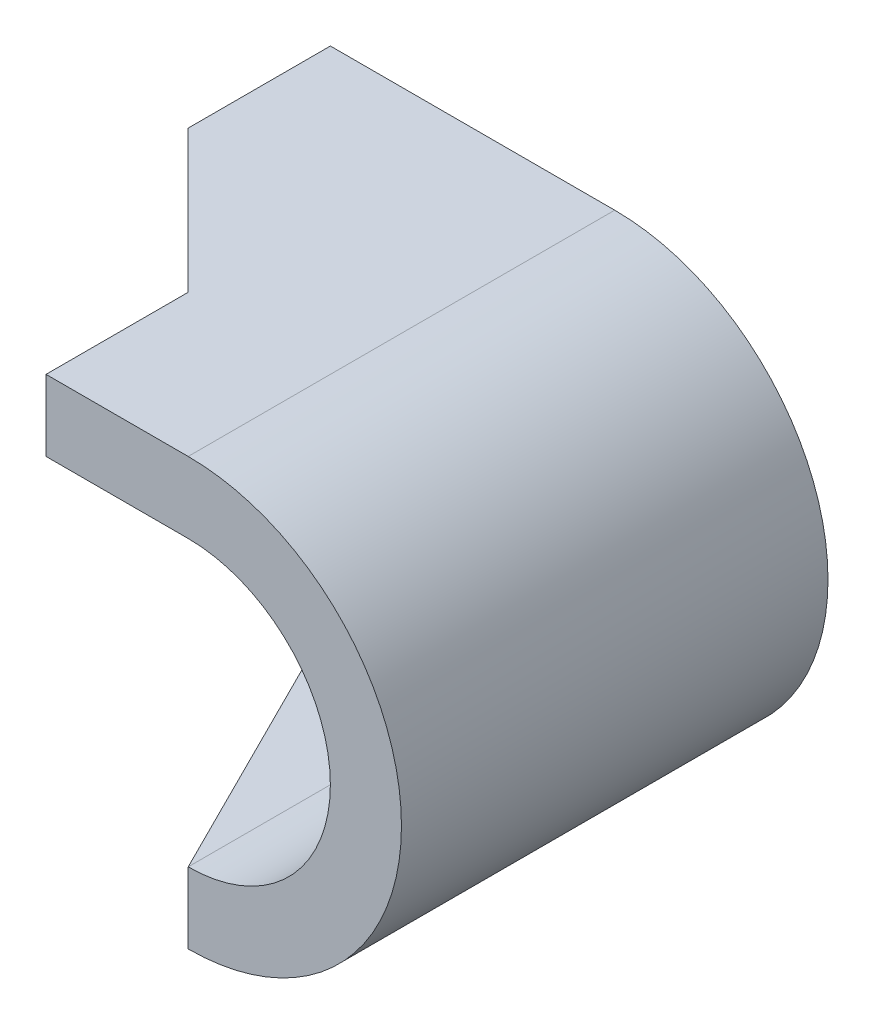
from build123d import *

# Parameters (mm, degrees)
BOSS_EXTRUDE1_DEPTH = 6
CUT_EXTRUDE1_DEPTH  = 6
CUT_EXTRUDE2_DEPTH  = 1


with BuildPart() as part:
    # Sketch2 → Boss-Extrude1 (new body)
    with BuildSketch(Plane.XY):
        with BuildLine():
            Line((0, 2), (-4, 2))
            Line((-4, 2), (-4, 3))
            Line((-4, 3), (0, 3))
            ThreePointArc((0, 3), (3, 0), (0, -3))
            Line((0, -3), (-2, -3))
            Line((-2, -3), (-2, -2))
            Line((-2, -2), (0, -2))
            ThreePointArc((0, -2), (2, 0), (0, 2))
        make_face()
    extrude(amount=BOSS_EXTRUDE1_DEPTH)

    # Sketch3 → Cut-Extrude1 (cut)
    with BuildSketch(Plane.XZ.offset(-2)):
        Polygon((-2, 6), (-2, 4), (-4, 2), (-4, 6), align=None)
    extrude(amount=-CUT_EXTRUDE1_DEPTH, mode=Mode.SUBTRACT)

    # Sketch4 → Cut-Extrude2 (cut)
    with BuildSketch(Plane.XZ.offset(3)):
        Polygon((0, 6), (-2, 2), (-2, 6), align=None)
    extrude(amount=-CUT_EXTRUDE2_DEPTH, mode=Mode.SUBTRACT)


solid = part.part
